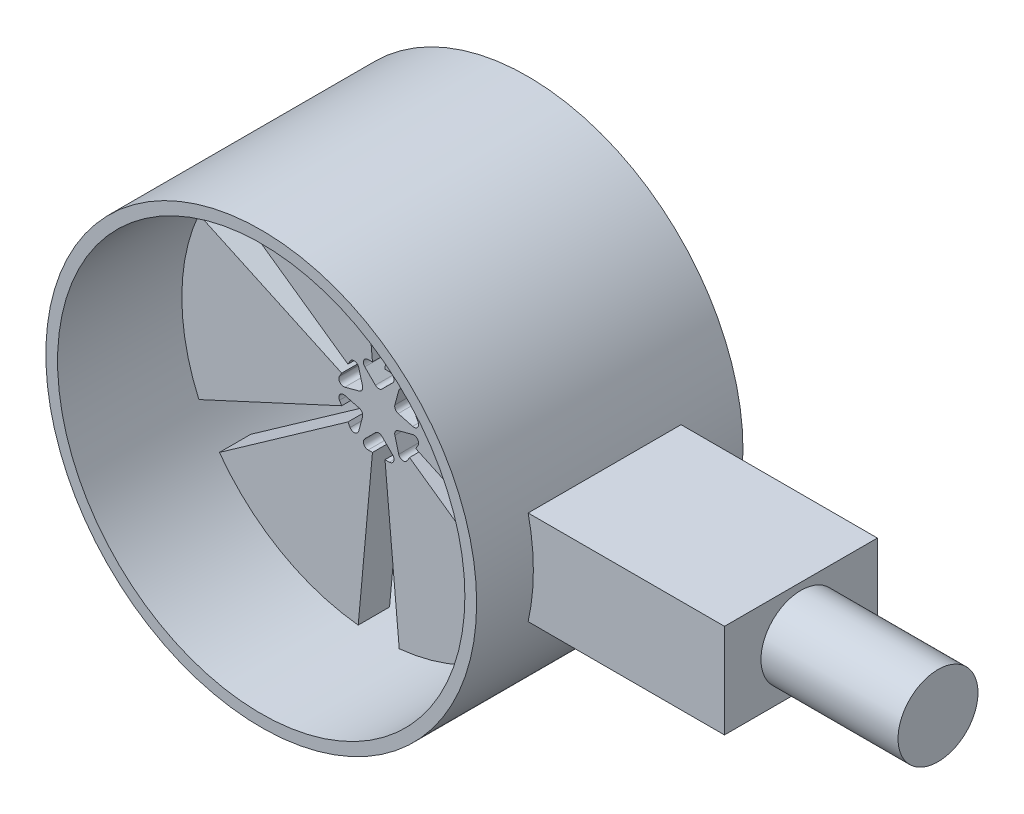
from build123d import *

# Parameters (mm, degrees)
SKETCH1_R           = 34.925
SKETCH1_R_2         = 33.02
BOSS_EXTRUDE1_DEPTH = 21.59
SKETCH2_R           = 31.923615123
BOSS_EXTRUDE2_DEPTH = 2.54
SKETCH5_W           = 24.790572848
SKETCH5_H           = 15.257559682
BOSS_EXTRUDE3_DEPTH = 32.385
CUT_EXTRUDE1_DEPTH  = 5.08
CIRPATTERN1_COUNT   = 6
SKETCH6_R           = 6.483320969
BOSS_EXTRUDE4_DEPTH = 22.225


with BuildPart() as part:
    # Sketch1 → Boss-Extrude1 (new body, symmetric)
    with BuildSketch(Plane.XY):
        Circle(SKETCH1_R)
        Circle(SKETCH1_R_2, mode=Mode.SUBTRACT)
    extrude(amount=BOSS_EXTRUDE1_DEPTH, both=True)

    # Sketch5 → Boss-Extrude3 (add)
    with BuildSketch(Plane(origin=(33.528, 0, 0), x_dir=(0, 0, -1), z_dir=(1, 0, 0))):
        Rectangle(SKETCH5_W, SKETCH5_H)
    extrude(amount=BOSS_EXTRUDE3_DEPTH)

    # Sketch6 → Boss-Extrude4 (add)
    with BuildSketch(Plane(origin=(65.913, 0, 0), x_dir=(0, 0, -1), z_dir=(1, 0, 0))):
        Circle(SKETCH6_R)
    extrude(amount=BOSS_EXTRUDE4_DEPTH)


with BuildPart() as body_2:
    # Sketch2 → Boss-Extrude2 (new body, symmetric)
    with BuildSketch(Plane.XY):
        Circle(SKETCH2_R)
    extrude(amount=BOSS_EXTRUDE2_DEPTH, both=True)

    # Sketch3 → Cut-Extrude1 (cut)
    with BuildSketch(Plane.XY.offset(2.54)):
        with BuildLine():
            Line((-3.324861274, 31.75), (-1.016, 6.35))
            Line((-1.016, 6.35), (-1.716369265, 6.35))
            ThreePointArc((-1.716369265, 6.35), (-2.420365469, 5.879604775), (-2.255184633, 5.049184633))
            Line((-2.255184633, 5.049184633), (-0.538815367, 3.332815367))
            ThreePointArc((-0.538815367, 3.332815367), (0, 3.109630735), (0.538815367, 3.332815367))
            Line((0.538815367, 3.332815367), (2.255184633, 5.049184633))
            ThreePointArc((2.255184633, 5.049184633), (2.420365469, 5.879604775), (1.716369265, 6.35))
            Line((1.716369265, 6.35), (1.016, 6.35))
            Line((1.016, 6.35), (3.324861274, 31.75))
            add(Edge.make_bspline(
                [(-3.324861274, 31.75), (0.001766049, 32.262077943), (3.324861274, 31.75)],
                knots=[0, 0, 0, 1, 1, 1], degree=2))
        make_face()
    cut_extrude1 = extrude(amount=-CUT_EXTRUDE1_DEPTH, mode=Mode.SUBTRACT)

    # CirPattern1: Cut-Extrude1 ×6 about axis
    cirpattern1_axis = Axis((0, 0, 0), (0, 0, 1))
    for i in range(1, CIRPATTERN1_COUNT):
        add(cut_extrude1.rotate(cirpattern1_axis, i * 360 / CIRPATTERN1_COUNT), mode=Mode.SUBTRACT)


solid = Compound([part.part, body_2.part])
